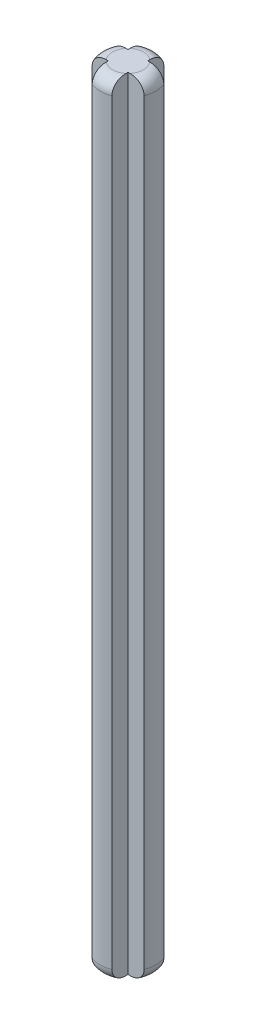
from build123d import *

# Parameters (mm, degrees)
BOSS_EXTRUDE1_DEPTH = 63.3
FILLET1_R           = 1
FILLET2_R           = 1
FILLET3_R           = 1
FILLET4_R           = 1
FILLET20_R          = 1
FILLET21_R          = 1
FILLET22_R          = 1
FILLET23_R          = 1


with BuildPart() as part:
    # Sketch1 → Boss-Extrude1 (new body)
    with BuildSketch(Plane(origin=(0, 0, 0), x_dir=(1, 0, 0), z_dir=(0, 1, 0))):
        with BuildLine():
            Line((-0.8, -0.8), (-0.8, -2.102974084))
            ThreePointArc((-0.8, -2.102974084), (0, -2.25), (0.8, -2.102974084))
            Line((0.8, -2.102974084), (0.8, -0.8))
            Line((0.8, -0.8), (2.102974084, -0.8))
            ThreePointArc((2.102974084, -0.8), (2.25, 0), (2.102974084, 0.8))
            Line((2.102974084, 0.8), (0.8, 0.8))
            Line((0.8, 0.8), (0.8, 2.102974084))
            ThreePointArc((0.8, 2.102974084), (0, 2.25), (-0.8, 2.102974084))
            Line((-0.8, 2.102974084), (-0.8, 0.8))
            Line((-0.8, 0.8), (-2.102974084, 0.8))
            ThreePointArc((-2.102974084, 0.8), (-2.25, 0), (-2.102974084, -0.8))
            Line((-2.102974084, -0.8), (-0.8, -0.8))
        make_face()
    extrude(amount=BOSS_EXTRUDE1_DEPTH)

    # Fillet1
    fillet1_edges = [part.edges().sort_by_distance(p)[0] for p in [
        (-2.25, 0, 0),
    ]]
    fillet(fillet1_edges, radius=FILLET1_R)

    # Fillet2
    fillet2_edges = [part.edges().sort_by_distance(p)[0] for p in [
        (0, 0, 2.25),
    ]]
    fillet(fillet2_edges, radius=FILLET2_R)

    # Fillet3
    fillet3_edges = [part.edges().sort_by_distance(p)[0] for p in [
        (2.25, 0, 0),
    ]]
    fillet(fillet3_edges, radius=FILLET3_R)

    # Fillet4
    fillet4_edges = [part.edges().sort_by_distance(p)[0] for p in [
        (0, 0, -2.25),
    ]]
    fillet(fillet4_edges, radius=FILLET4_R)

    # Fillet20
    fillet20_edges = [part.edges().sort_by_distance(p)[0] for p in [
        (2.25, 63.3, 0),
    ]]
    fillet(fillet20_edges, radius=FILLET20_R)

    # Fillet21
    fillet21_edges = [part.edges().sort_by_distance(p)[0] for p in [
        (0, 63.3, 2.25),
    ]]
    fillet(fillet21_edges, radius=FILLET21_R)

    # Fillet22
    fillet22_edges = [part.edges().sort_by_distance(p)[0] for p in [
        (-2.25, 63.3, 0),
    ]]
    fillet(fillet22_edges, radius=FILLET22_R)

    # Fillet23
    fillet23_edges = [part.edges().sort_by_distance(p)[0] for p in [
        (0, 63.3, -2.25),
    ]]
    fillet(fillet23_edges, radius=FILLET23_R)


solid = part.part
